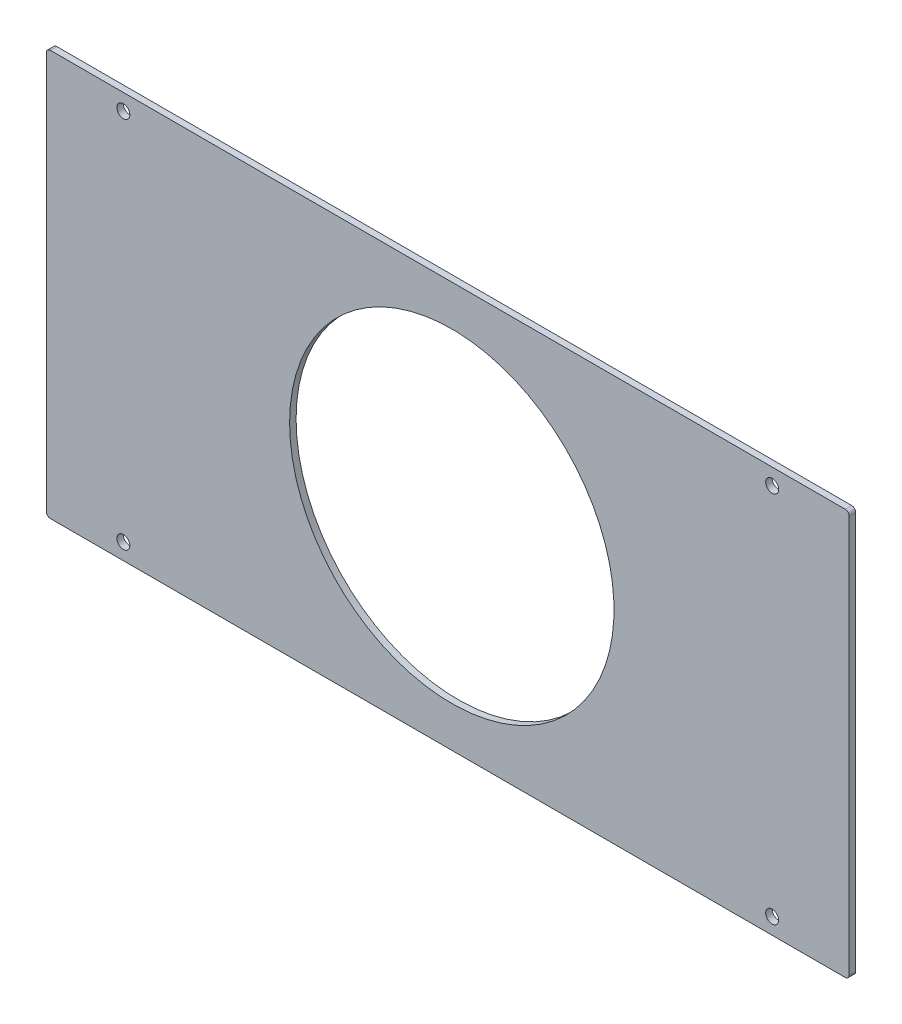
from build123d import *

# Parameters (mm, degrees)
BOSS_EXTRU_1_DEPTH      = 1.6
ESQUISSE3_R             = 1.6
ESQUISSE3_R_2           = 40
ENL_V_MAT_EXTRU_1_DEPTH = 2.6


with BuildPart() as part:
    # Esquisse1 → Boss.-Extru.1 (new body)
    with BuildSketch(Plane.XY):
        with BuildLine():
            Line((1, 0), (197, 0))
            ThreePointArc((197, 0), (197.707106781, 0.292893219), (198, 1))
            Line((198, 1), (198, 99))
            ThreePointArc((198, 99), (197.707106781, 99.707106781), (197, 100))
            Line((197, 100), (1, 100))
            ThreePointArc((1, 100), (0.292893219, 99.707106781), (0, 99))
            Line((0, 99), (0, 1))
            ThreePointArc((0, 1), (0.292893219, 0.292893219), (1, 0))
        make_face()
    extrude(amount=BOSS_EXTRU_1_DEPTH)

    # Esquisse3 → Enlèv. mat.-Extru.1 (cut, through all)
    with BuildSketch(Plane(origin=(0, 0, 0), x_dir=(-1, 0, 0), z_dir=(0, 0, -1))):
        with Locations((-179, 96)):
            Circle(ESQUISSE3_R)
        with Locations((-179, 4)):
            Circle(ESQUISSE3_R)
        with Locations((-19, 4)):
            Circle(ESQUISSE3_R)
        with Locations((-19, 96)):
            Circle(ESQUISSE3_R)
        with Locations((-100, 50)):
            Circle(ESQUISSE3_R_2)
    extrude(amount=-ENL_V_MAT_EXTRU_1_DEPTH, mode=Mode.SUBTRACT)


solid = part.part
